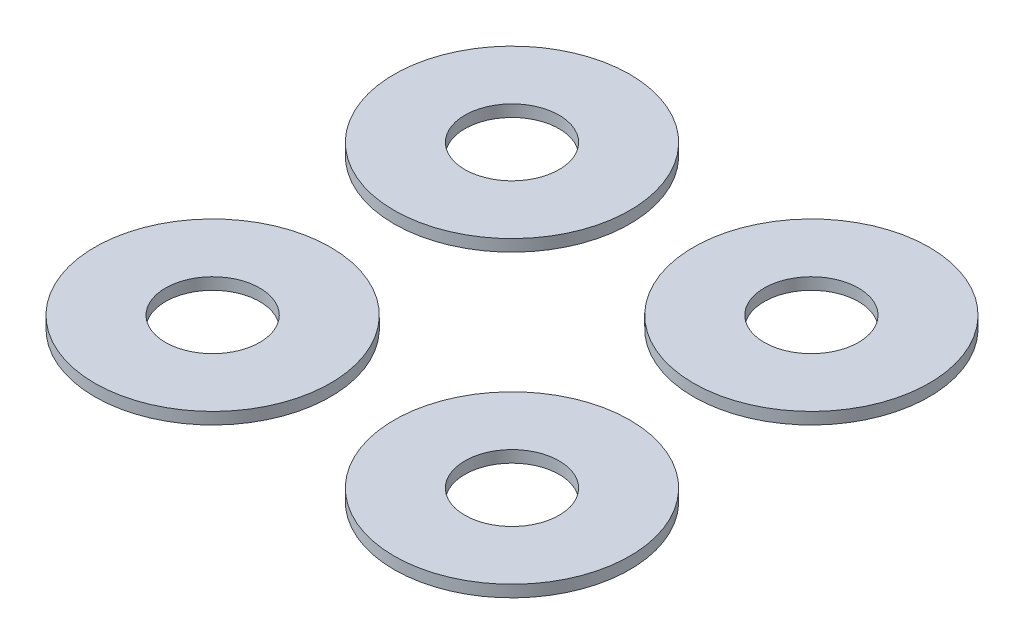
from build123d import *

# Parameters (mm, degrees)
SKETCH1_R             = 1
SKETCH1_R_2           = 0.4
BOSS_EXTRUDE1_DEPTH   = 0.1
BOSS_EXTRUDE1_2_DEPTH = 0.1
BOSS_EXTRUDE1_3_DEPTH = 0.1
BOSS_EXTRUDE1_4_DEPTH = 0.1


with BuildPart() as part:
    # Sketch1 → Boss-Extrude1 (new body)
    with BuildSketch(Plane(origin=(0, 0, 0), x_dir=(1, 0, 0), z_dir=(0, 1, 0))):
        Circle(SKETCH1_R)
        Circle(SKETCH1_R_2, mode=Mode.SUBTRACT)
    extrude(amount=BOSS_EXTRUDE1_DEPTH)


with BuildPart() as body_2:
    # Sketch1 → Boss-Extrude1 2 (new body)
    with BuildSketch(Plane(origin=(0, 0, 0), x_dir=(1, 0, 0), z_dir=(0, 1, 0))):
        with Locations((0, 2.54)):
            Circle(SKETCH1_R)
        with Locations((0, 2.54)):
            Circle(SKETCH1_R_2, mode=Mode.SUBTRACT)
    extrude(amount=BOSS_EXTRUDE1_2_DEPTH)


with BuildPart() as body_3:
    # Sketch1 → Boss-Extrude1 3 (new body)
    with BuildSketch(Plane(origin=(0, 0, 0), x_dir=(1, 0, 0), z_dir=(0, 1, 0))):
        with Locations((2.54, 2.54)):
            Circle(SKETCH1_R)
        with Locations((2.54, 2.54)):
            Circle(SKETCH1_R_2, mode=Mode.SUBTRACT)
    extrude(amount=BOSS_EXTRUDE1_3_DEPTH)


with BuildPart() as body_4:
    # Sketch1 → Boss-Extrude1 4 (new body)
    with BuildSketch(Plane(origin=(0, 0, 0), x_dir=(1, 0, 0), z_dir=(0, 1, 0))):
        with Locations((2.54, 0)):
            Circle(SKETCH1_R)
        with Locations((2.54, 0)):
            Circle(SKETCH1_R_2, mode=Mode.SUBTRACT)
    extrude(amount=BOSS_EXTRUDE1_4_DEPTH)


solid = Compound([part.part, body_2.part, body_3.part, body_4.part])
